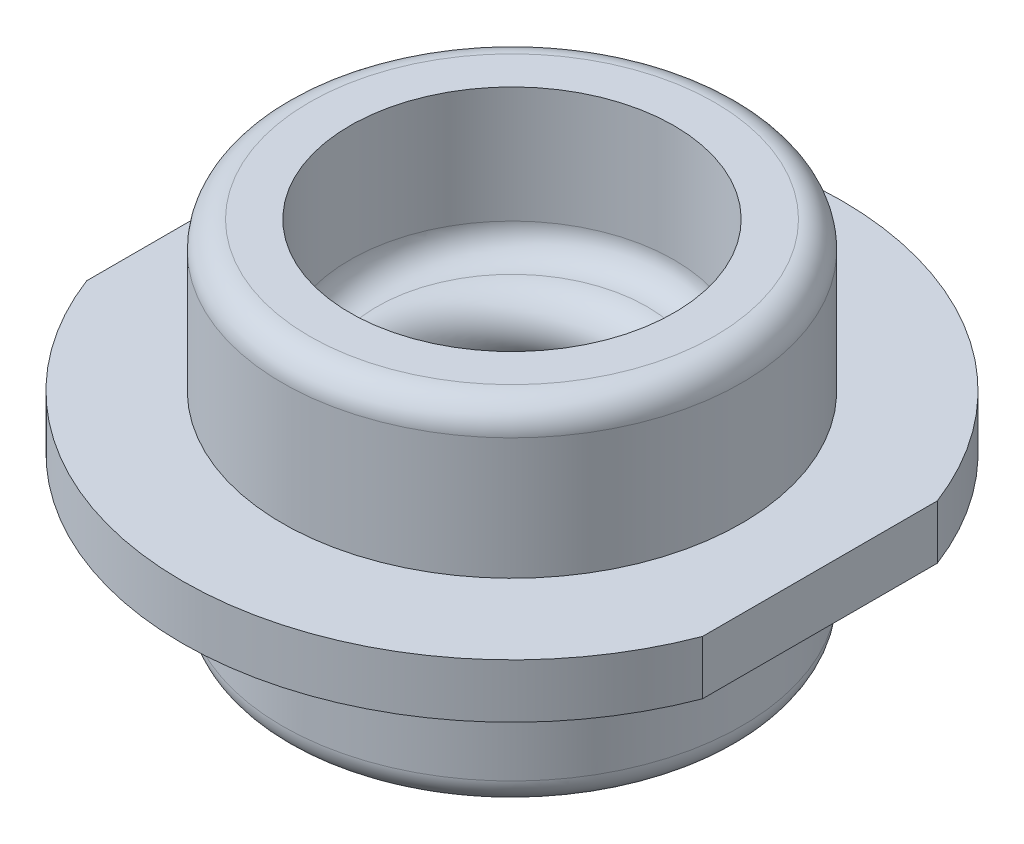
from build123d import *

# Parameters (mm, degrees)
FILLET1_R          = 0.127
SKETCH2_W          = 1.656655401
SKETCH2_H          = 3.010652604
CUT_EXTRUDE1_DEPTH = 1.27


with BuildPart() as part:
    # Sketch1 → Revolve1 (revolve)
    with BuildSketch(Plane.XY):
        with BuildLine():
            Line((-1.0795, 0.8255), (-1.0795, 0.127))
            Line((-1.0795, 0.127), (-1.5494, 0.127))
            Line((-1.5494, 0.127), (-1.5494, -0.127))
            Line((-1.5494, -0.127), (-1.0795, -0.127))
            Line((-1.0795, -0.127), (-1.0795, -0.8255))
            Line((-1.0795, -0.8255), (-0.762, -0.8255))
            Line((-0.762, -0.8255), (-0.762, -0.2794))
            ThreePointArc((-0.762, -0.2794), (-0.724802561, -0.189597439), (-0.635, -0.1524))
            ThreePointArc((-0.635, -0.1524), (-0.527236927, -0.107763073), (-0.4826, 0))
            ThreePointArc((-0.4826, 0), (-0.527236927, 0.107763073), (-0.635, 0.1524))
            ThreePointArc((-0.635, 0.1524), (-0.724802561, 0.189597439), (-0.762, 0.2794))
            Line((-0.762, 0.2794), (-0.762, 0.8255))
            Line((-0.762, 0.8255), (-1.0795, 0.8255))
        make_face()
    revolve(axis=Axis((0, 0, 0), (0, 1, 0)))

    # Fillet1
    fillet1_edges = [part.edges().sort_by_distance(p)[0] for p in [
        (1.0795, -0.8255, 0),
        (1.0795, 0.8255, 0),
    ]]
    fillet(fillet1_edges, radius=FILLET1_R)

    # Sketch2 → Cut-Extrude1 (cut, symmetric)
    with BuildSketch(Plane(origin=(0, 0, 0), x_dir=(1, 0, 0), z_dir=(0, 1, 0))):
        with Locations((-2.276127701, -0.051770481)):
            Rectangle(SKETCH2_W, SKETCH2_H)
        with Locations((2.276127701, -0.051770481)):
            Rectangle(SKETCH2_W, SKETCH2_H)
    extrude(amount=CUT_EXTRUDE1_DEPTH, both=True, mode=Mode.SUBTRACT)


solid = part.part
